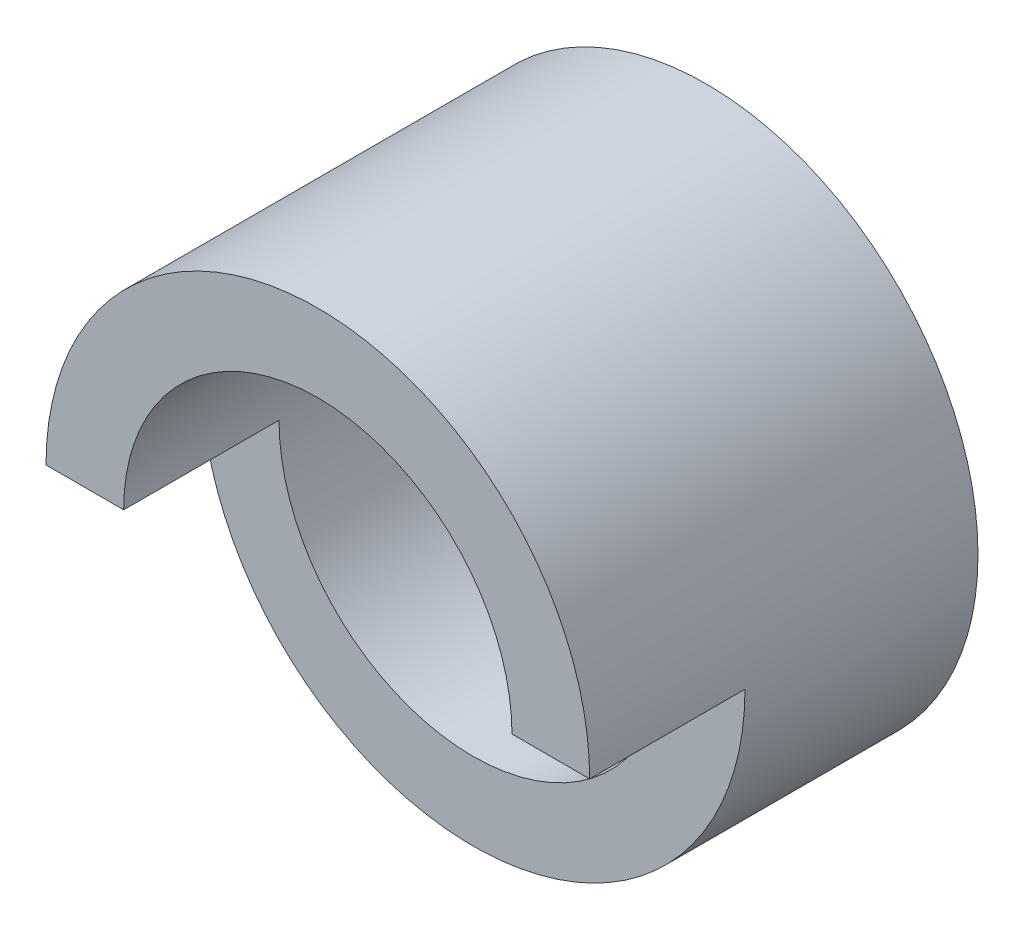
from build123d import *

# Parameters (mm, degrees)
SKETCH1_R           = 7
SKETCH1_R_2         = 5
BOSS_EXTRUDE1_DEPTH = 10
SKETCH3_W           = 4
SKETCH3_H           = 7
CUT_EXTRUDE1_DEPTH  = 10


with BuildPart() as part:
    # Sketch1 → Boss-Extrude1 (new body)
    with BuildSketch(Plane.XY):
        Circle(SKETCH1_R)
        Circle(SKETCH1_R_2, mode=Mode.SUBTRACT)
    extrude(amount=BOSS_EXTRUDE1_DEPTH)

    # Sketch3 → Cut-Extrude1 (cut, symmetric)
    with BuildSketch(Plane(origin=(0, 0, 0), x_dir=(0, 0, -1), z_dir=(1, 0, 0))):
        with Locations((-8, -3.5)):
            Rectangle(SKETCH3_W, SKETCH3_H)
    extrude(amount=CUT_EXTRUDE1_DEPTH, both=True, mode=Mode.SUBTRACT)


solid = part.part
